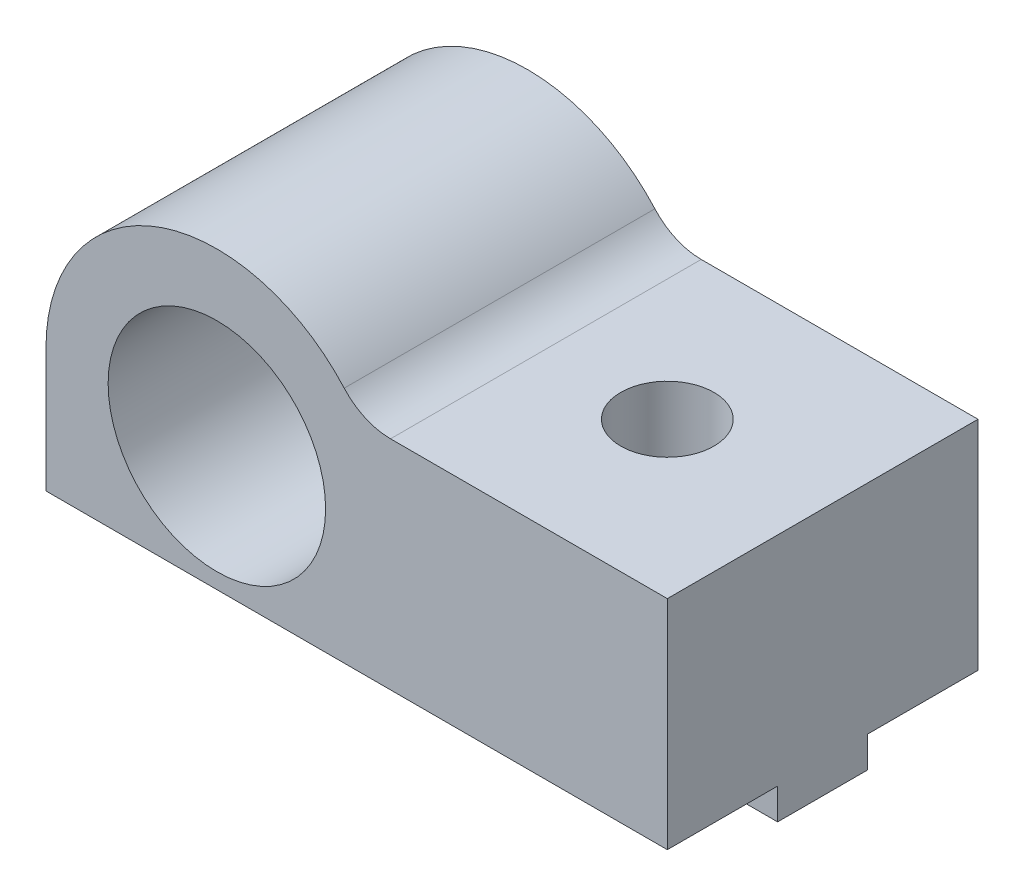
from build123d import *

# Parameters (mm, degrees)
SKETCH1_R                       = 3.5
MAIN_DEPTH                      = 10
SKETCH3_W                       = 20
SKETCH3_H                       = 2.9
MAKERBEAMRECTANGULARGUIDE_DEPTH = 1
SKETCH4_R                       = 1.5
MAKERBEAMFIXHOLE_DEPTH          = 9
FILLET1_R                       = 2


with BuildPart() as part:
    # Sketch1 → Main (new body)
    with BuildSketch(Plane.XY):
        with BuildLine():
            Line((-5.5, 0), (-5.5, -4))
            Line((-5.5, -4), (14.5, -4))
            Line((14.5, -4), (14.5, 3))
            Line((14.5, 3), (4.609772229, 3))
            ThreePointArc((4.609772229, 3), (-1.564648961, 5.272748205), (-5.5, 0))
        make_face()
        Circle(SKETCH1_R, mode=Mode.SUBTRACT)
    extrude(amount=MAIN_DEPTH)

    # Sketch3 → MakerBeamRectangularGuide (add)
    with BuildSketch(Plane(origin=(0, -4, 0), x_dir=(-1, 0, 0), z_dir=(0, -1, 0))):
        with Locations((-4.5, -5)):
            Rectangle(SKETCH3_W, SKETCH3_H)
    extrude(amount=MAKERBEAMRECTANGULARGUIDE_DEPTH)

    # Sketch4 → MakerBeamFixHole (cut, through all)
    with BuildSketch(Plane(origin=(0, 3, 0), x_dir=(1, 0, 0), z_dir=(0, 1, 0))):
        with Locations((9.5, -5)):
            Circle(SKETCH4_R)
    extrude(amount=-MAKERBEAMFIXHOLE_DEPTH, mode=Mode.SUBTRACT)

    # Fillet1
    fillet1_edges = [part.edges().sort_by_distance(p)[0] for p in [
        (4.609772229, 3, 5),
    ]]
    fillet(fillet1_edges, radius=FILLET1_R)


solid = part.part
